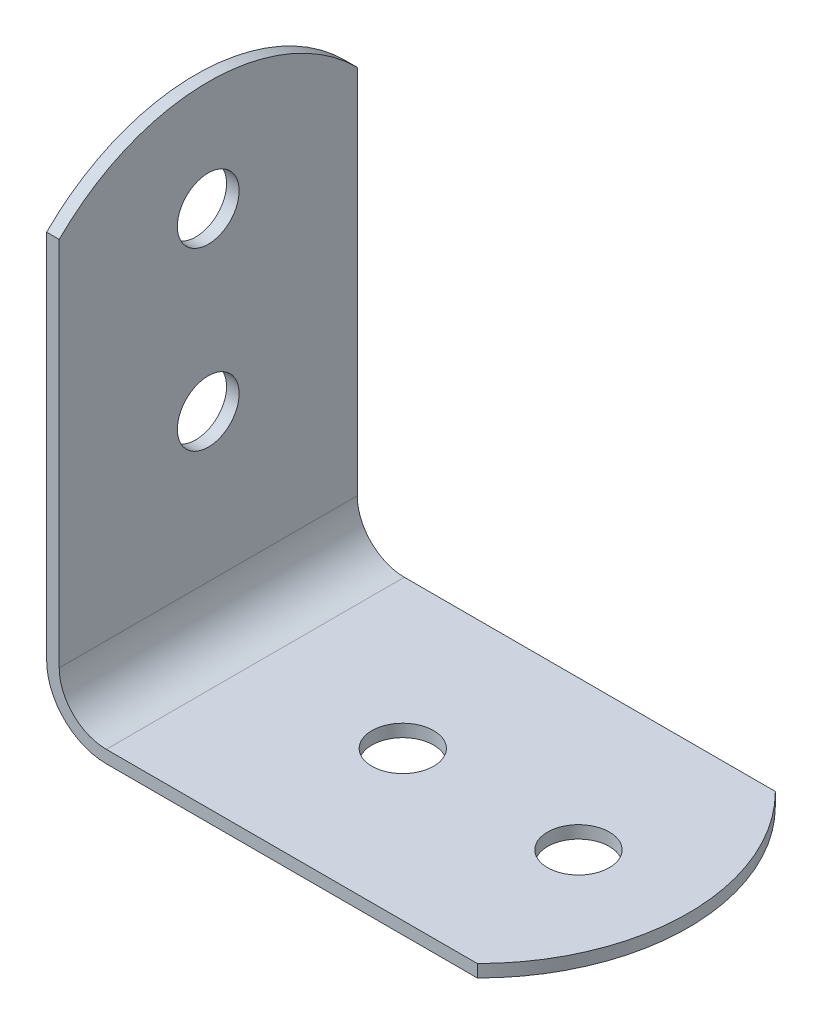
from build123d import *

# Parameters (mm, degrees)
BOSS_EXTRUDE1_DEPTH   = 24.13
FILLET1_R             = 3.81
FILLET2_R             = 4.826
F_5_0MM_DOWEL_HOLE1_D = 5
F_5_0MM_DOWEL_HOLE2_D = 5
CUT_EXTRUDE1_DEPTH    = 40.878
CUT_EXTRUDE2_DEPTH    = 40.878


with BuildPart() as part:
    # Sketch1 → Boss-Extrude1 (new body)
    with BuildSketch(Plane.XY):
        Polygon((0, 39.878), (0, 0), (39.878, 0), (39.878, 1.016), (1.016, 1.016), (1.016, 39.878), align=None)
    extrude(amount=BOSS_EXTRUDE1_DEPTH)

    # Fillet1
    fillet1_edges = [part.edges().sort_by_distance(p)[0] for p in [
        (1.016, 1.016, 12.065),
    ]]
    fillet(fillet1_edges, radius=FILLET1_R)

    # Fillet2
    fillet2_edges = [part.edges().sort_by_distance(p)[0] for p in [
        (0, 0, 12.065),
    ]]
    fillet(fillet2_edges, radius=FILLET2_R)

    # Ø5.0mm Dowel Hole1 (through all)
    with Locations(Plane.ZY):
        with Locations((12.065, 30.988), (12.065, 16.764)):
            Hole(F_5_0MM_DOWEL_HOLE1_D / 2)

    # Ø5.0mm Dowel Hole2 (through all)
    with Locations(Plane(origin=(0, 0, 0), x_dir=(-1, 0, 0), z_dir=(0, -1, 0))):
        with Locations((-30.988, -12.065), (-16.764, -12.065)):
            Hole(F_5_0MM_DOWEL_HOLE2_D / 2)

    # Sketch6 → Cut-Extrude1 (cut, through all)
    with BuildSketch(Plane.XZ):
        with BuildLine():
            Line((34.862003958, 24.13), (44.45, 24.13))
            Line((44.45, 24.13), (44.45, 0))
            Line((44.45, 0), (34.862003958, 0))
            ThreePointArc((34.862003958, 0), (39.878, 12.065), (34.862003958, 24.13))
        make_face()
    extrude(amount=-CUT_EXTRUDE1_DEPTH, mode=Mode.SUBTRACT)

    # Sketch7 → Cut-Extrude2 (cut, through all)
    with BuildSketch(Plane.ZY):
        with BuildLine():
            Line((0, 34.862003958), (0, 44.45))
            Line((0, 44.45), (24.13, 44.45))
            Line((24.13, 44.45), (24.13, 34.862003958))
            ThreePointArc((24.13, 34.862003958), (12.065, 39.878), (0, 34.862003958))
        make_face()
    extrude(amount=-CUT_EXTRUDE2_DEPTH, mode=Mode.SUBTRACT)


solid = part.part
